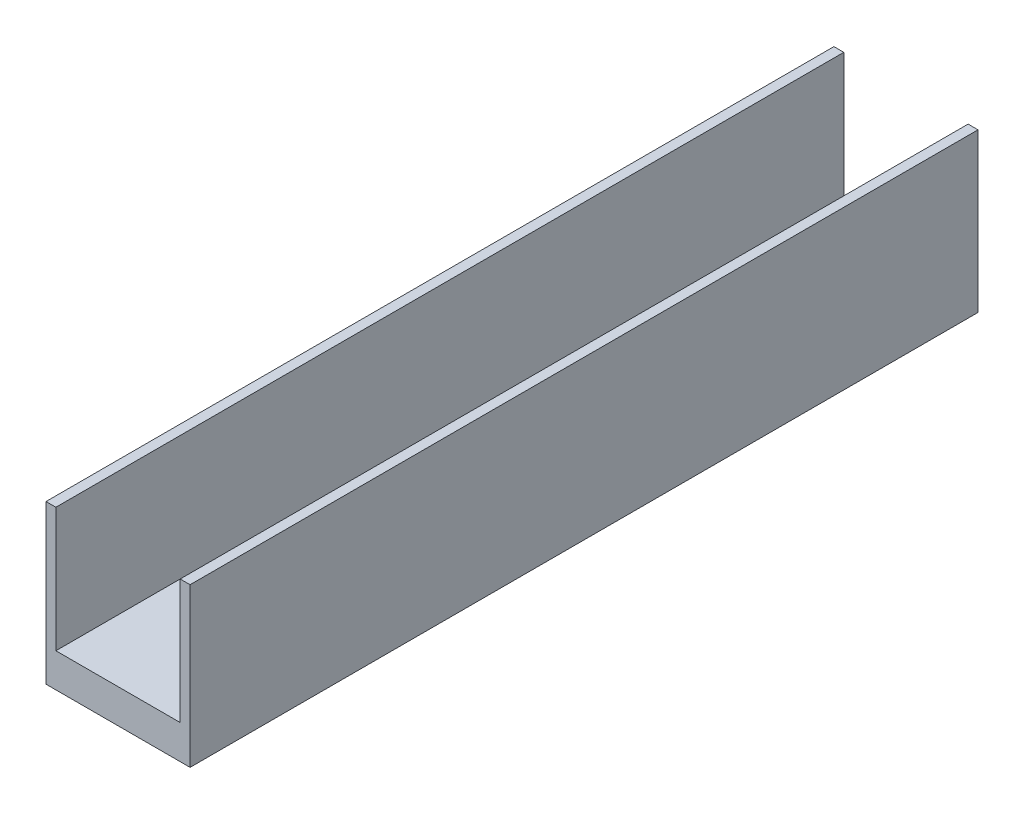
from build123d import *

# Parameters (mm, degrees)
BOSS_EXTRUDE1_DEPTH = 442.7347


with BuildPart() as part:
    # Sketch1 → Boss-Extrude1 (new body)
    with BuildSketch(Plane.XY):
        Polygon((0, 0), (0, 88.9), (5.55625, 88.9), (5.55625, 19.05), (75.40625, 19.05), (75.40625, 88.9), (80.9625, 88.9), (80.9625, 0), align=None)
    extrude(amount=BOSS_EXTRUDE1_DEPTH)


solid = part.part
